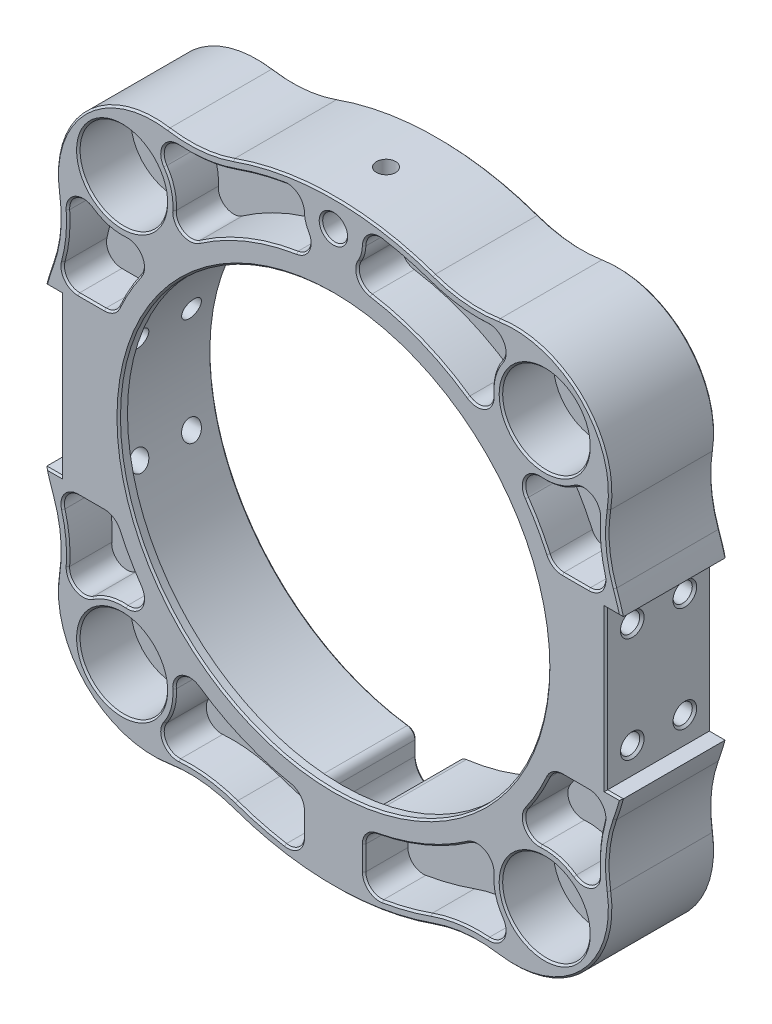
from build123d import *

# Parameters (mm, degrees)
SKETCH1_R                       = 5
EXTRUDE1_DEPTH                  = 12
SKETCH2_R                       = 24.5
EXTRUDE2_DEPTH                  = 13
SKETCH3_R                       = 5
FLAG_STOP_DEPTH_DEPTH           = 6
EXTRUDE4_DEPTH                  = 11
SKETCH5_R                       = 2.5
EXTRUDE5_DEPTH                  = 7
SKETCH6_R                       = 4.3
FLAG_MOUNTING_DEPTH_DEPTH       = 5
SKETCH7_W                       = 12
SKETCH7_H                       = 18
EXTRUDE7_DEPTH                  = 4
SKETCH8_R                       = 1.1
EXTRUDE8_DEPTH                  = 17
CHAMFER1_SIZE                   = 0.25
CHAMFER1_OF_MIRROR1_SIZE        = 0.25
SKETCH9_R                       = 1.4224
EXTRUDE9_DEPTH                  = 13
SKETCH11_R                      = 1.4224
EXTRUDE11_DEPTH                 = 43
EXTRUDE12_DEPTH                 = 5
EXTRUDE13_DEPTH                 = 5
EXTRUDE14_DEPTH                 = 5
MIRROR7_COPY_1_DEPTH            = 5
MIRROR8_COPY_1_DEPTH            = 5
MIRROR8_COPY_2_DEPTH            = 5
MIRROR8_COPY_3_DEPTH            = 5
MIRROR8_COPY_4_DEPTH            = 5
CHAMFER2_SIZE                   = 0.2
CHAMFER3_SIZE                   = 0.2
F_2_56_TAPPED_HOLE1_D           = 1.778
F_2_56_TAPPED_HOLE1_DEPTH       = 3.1
F_2_56_TAPPED_HOLE1_CBORE_D     = 2.1844
F_2_56_TAPPED_HOLE1_CBORE_DEPTH = 3
F_2_56_TAPPED_HOLE1_TIP         = 0.53416509


with BuildPart() as part:
    # Sketch1 → Extrude1 (new body)
    with BuildSketch(Plane.XY):
        with BuildLine():
            ThreePointArc((-32.122002379, 11.444953611), (-34.1, 0), (-32.122002379, -11.444953611))
            ThreePointArc((-32.122002379, -11.444953611), (-31.315364719, -15.101184494), (-31.439353074, -18.843284904))
            ThreePointArc((-31.439353074, -18.843284904), (-28.354981926, -28.354981926), (-18.843284904, -31.439353074))
            ThreePointArc((-18.843284904, -31.439353074), (-15.101184494, -31.315364719), (-11.444953611, -32.122002379))
            ThreePointArc((-11.444953611, -32.122002379), (0, -34.1), (11.444953611, -32.122002379))
            ThreePointArc((11.444953611, -32.122002379), (15.101184494, -31.315364719), (18.843284904, -31.439353074))
            ThreePointArc((18.843284904, -31.439353074), (28.354981926, -28.354981925), (31.439353074, -18.843284904))
            ThreePointArc((31.439353074, -18.843284904), (31.315364719, -15.101184494), (32.122002379, -11.444953611))
            ThreePointArc((32.122002379, -11.444953611), (34.1, 0), (32.122002379, 11.444953611))
            ThreePointArc((32.122002379, 11.444953611), (31.315364719, 15.101184494), (31.439353074, 18.843284904))
            ThreePointArc((31.439353074, 18.843284904), (28.354981926, 28.354981926), (18.843284904, 31.439353074))
            ThreePointArc((18.843284904, 31.439353074), (15.101184494, 31.31536472), (11.444953611, 32.122002379))
            ThreePointArc((11.444953611, 32.122002379), (0, 34.1), (-11.444953611, 32.122002379))
            ThreePointArc((-11.444953611, 32.122002379), (-15.101184494, 31.315364719), (-18.843284904, 31.439353074))
            ThreePointArc((-18.843284904, 31.439353074), (-28.354981926, 28.354981926), (-31.439353074, 18.843284904))
            ThreePointArc((-31.439353074, 18.843284904), (-31.315364719, 15.101184494), (-32.122002379, 11.444953611))
        make_face()
        with Locations((-24.112341238, 24.112341238)):
            Circle(SKETCH1_R, mode=Mode.SUBTRACT)
        with Locations((24.112341238, 24.112341239)):
            Circle(SKETCH1_R, mode=Mode.SUBTRACT)
        with Locations((24.112341238, -24.112341238)):
            Circle(SKETCH1_R, mode=Mode.SUBTRACT)
        with Locations((-24.112341238, -24.112341238)):
            Circle(SKETCH1_R, mode=Mode.SUBTRACT)
    extrude(amount=EXTRUDE1_DEPTH)

    # Sketch2 → Extrude2 (cut, through all)
    with BuildSketch(Plane.XY.offset(12)):
        Circle(SKETCH2_R)
    extrude(amount=-EXTRUDE2_DEPTH, mode=Mode.SUBTRACT)

    # Sketch3 → Flag Stop Depth (add)
    with BuildSketch(Plane(origin=(0, 0, 0), x_dir=(-1, 0, 0), z_dir=(0, 0, -1))):
        with Locations((24.112341238, 24.112341238)):
            Circle(SKETCH3_R)
        with Locations((24.112341238, -24.112341238)):
            Circle(SKETCH3_R)
        with Locations((-24.112341238, -24.112341238)):
            Circle(SKETCH3_R)
        with Locations((-24.112341238, 24.112341239)):
            Circle(SKETCH3_R)
    extrude(amount=-FLAG_STOP_DEPTH_DEPTH)

    # Sketch4 → Extrude4 (cut)
    with BuildSketch(Plane(origin=(0, 0, 0), x_dir=(-1, 0, 0), z_dir=(0, 0, -1))):
        with BuildLine():
            Line((-2.5, -28.3), (-2.5, -26.671332925))
            ThreePointArc((-2.5, -26.671332925), (-2.74829809, -26.011829902), (-3.369888476, -25.67983356))
            ThreePointArc((-3.369888476, -25.67983356), (-24.176682626, -9.289672611), (-19.698530393, 16.816001319))
            ThreePointArc((-19.698530393, 16.816001319), (-19.088675937, 17.359183498), (-18.354926101, 17.717764752))
            ThreePointArc((-18.354926101, 17.717764752), (-17.960512242, 17.960512242), (-17.717764752, 18.354926101))
            ThreePointArc((-17.717764752, 18.354926101), (-17.359183498, 19.088675937), (-16.816001319, 19.698530393))
            ThreePointArc((-16.816001319, 19.698530393), (0, 25.9), (16.816001319, 19.698530393))
            ThreePointArc((16.816001319, 19.698530393), (17.359183498, 19.088675937), (17.717764752, 18.354926101))
            ThreePointArc((17.717764752, 18.354926101), (17.960512242, 17.960512242), (18.354926101, 17.717764752))
            ThreePointArc((18.354926101, 17.717764752), (19.088675937, 17.359183498), (19.698530393, 16.816001319))
            ThreePointArc((19.698530393, 16.816001319), (24.176682626, -9.289672611), (3.369888476, -25.67983356))
            ThreePointArc((3.369888476, -25.67983356), (2.74829809, -26.011829902), (2.5, -26.671332925))
            Line((2.5, -26.671332925), (2.5, -28.3))
            ThreePointArc((2.5, -28.3), (0, -30.8), (-2.5, -28.3))
        make_face()
    extrude(amount=-EXTRUDE4_DEPTH, mode=Mode.SUBTRACT)

    # Sketch5 → Extrude5 (cut, through all)
    with BuildSketch(Plane.XY.offset(6)):
        with Locations((-24.112341238, 24.112341238)):
            Circle(SKETCH5_R)
        with Locations((24.112341238, 24.112341239)):
            Circle(SKETCH5_R)
        with Locations((24.112341238, -24.112341238)):
            Circle(SKETCH5_R)
        with Locations((-24.112341238, -24.112341238)):
            Circle(SKETCH5_R)
    extrude(amount=-EXTRUDE5_DEPTH, mode=Mode.SUBTRACT)

    # Sketch6 → Flag Mounting Depth (cut)
    with BuildSketch(Plane(origin=(0, 0, 0), x_dir=(-1, 0, 0), z_dir=(0, 0, -1))):
        with Locations((-24.112341238, 24.112341239)):
            Circle(SKETCH6_R)
        with Locations((24.112341238, 24.112341238)):
            Circle(SKETCH6_R)
        with Locations((24.112341238, -24.112341238)):
            Circle(SKETCH6_R)
        with Locations((-24.112341238, -24.112341238)):
            Circle(SKETCH6_R)
    extrude(amount=-FLAG_MOUNTING_DEPTH_DEPTH, mode=Mode.SUBTRACT)

    # Sketch7 → Extrude7 (cut, through all)
    with BuildSketch(Plane(origin=(31.1, 0, 0), x_dir=(0, 0, -1), z_dir=(1, 0, 0))):
        with Locations((-6, 0)):
            Rectangle(SKETCH7_W, SKETCH7_H)
    extrude7 = extrude(amount=EXTRUDE7_DEPTH, mode=Mode.SUBTRACT)

    # Sketch8 → Extrude8 (cut)
    with BuildSketch(Plane(origin=(31.1, 0, 0), x_dir=(0, 0, -1), z_dir=(1, 0, 0))):
        with Locations((-9, 6)):
            Circle(SKETCH8_R)
        with Locations((-3, 6)):
            Circle(SKETCH8_R)
        with Locations((-9, -6)):
            Circle(SKETCH8_R)
        with Locations((-3, -6)):
            Circle(SKETCH8_R)
    extrude8 = extrude(amount=-EXTRUDE8_DEPTH, mode=Mode.SUBTRACT)

    # Chamfer1
    chamfer1_edges = [part.edges().sort_by_distance(p)[0] for p in [
        (31.1, 6, 10.1),
        (31.1, 6, 4.1),
        (31.1, -6, 10.1),
        (31.1, -6, 4.1),
    ]]
    chamfer(chamfer1_edges, length=CHAMFER1_SIZE)

    # Mirror1: Extrude7, Extrude8 across plane
    add(extrude7.mirror(Plane(origin=(0, 0, 0), x_dir=(0, 0, 1), z_dir=(1, 0, 0))), mode=Mode.SUBTRACT)
    add(extrude8.mirror(Plane(origin=(0, 0, 0), x_dir=(0, 0, 1), z_dir=(1, 0, 0))), mode=Mode.SUBTRACT)

    # Chamfer1 of Mirror1
    chamfer1_of_mirror1_edges = [part.edges().sort_by_distance(p)[0] for p in [
        (-31.1, 6, 10.1),
        (-31.1, 6, 4.1),
        (-31.1, -6, 10.1),
        (-31.1, -6, 4.1),
    ]]
    chamfer(chamfer1_of_mirror1_edges, length=CHAMFER1_OF_MIRROR1_SIZE)

    # Sketch9 → Extrude9 (cut, through all)
    with BuildSketch(Plane(origin=(0, 0, 0), x_dir=(-1, 0, 0), z_dir=(0, 0, -1))):
        with Locations((0, 31)):
            Circle(SKETCH9_R)
    extrude(amount=-EXTRUDE9_DEPTH, mode=Mode.SUBTRACT)

    # Sketch11 → Extrude11 (cut)
    with BuildSketch(Plane(origin=(0, 0, 0), x_dir=(1, 0, 0), z_dir=(0, 1, 0))):
        with Locations(Location((0, -5.5, 0), (0, 0, 270))):  # turned: the seam where the file's is
            Circle(SKETCH11_R)
    extrude(amount=-EXTRUDE11_DEPTH, mode=Mode.SUBTRACT)

    # Sketch12 → Extrude12 (cut)
    with BuildSketch(Plane(origin=(0, 0, 0), x_dir=(-1, 0, 0), z_dir=(0, 0, -1))):
        with BuildLine():
            ThreePointArc((-4.224385639, 26.566229804), (-10.059879618, 24.948122616), (-15.385556887, 22.065689187))
            ThreePointArc((-15.385556887, 22.065689187), (-17.256662277, 21.982875917), (-18.131026227, 23.639191438))
            ThreePointArc((-18.131026227, 23.639191438), (-18.322112756, 25.684999536), (-19.192239457, 27.546376542))
            ThreePointArc((-19.192239457, 27.546376542), (-19.278714432, 29.412564625), (-17.631227608, 30.293429566))
            ThreePointArc((-17.631227608, 30.293429566), (-14.32419464, 30.397732089), (-11.109324473, 31.180008175))
            ThreePointArc((-11.109324473, 31.180008175), (-8.357386403, 32.027552084), (-5.542200264, 32.632713896))
            ThreePointArc((-5.542200264, 32.632713896), (-4.131919638, 32.254349629), (-3.499455756, 30.93827957))
            ThreePointArc((-3.499455756, 30.93827957), (-3.364163573, 30.034389595), (-2.999470844, 29.196344086))
            ThreePointArc((-2.999470844, 29.196344086), (-2.912814896, 27.555691101), (-4.224385639, 26.566229804))
        make_face()
    extrude12 = extrude(amount=-EXTRUDE12_DEPTH, mode=Mode.SUBTRACT)

    # Sketch13 → Extrude13 (cut)
    with BuildSketch(Plane(origin=(0, 0, 0), x_dir=(-1, 0, 0), z_dir=(0, 0, -1))):
        with BuildLine():
            Line((-29.143573514, 10), (-26.129676615, 10))
            ThreePointArc((-26.129676615, 10), (-25.179281731, 10.28056148), (-24.53362307, 11.032286213))
            ThreePointArc((-24.53362307, 11.032286213), (-23.40110504, 13.266434447), (-22.065689186, 15.385556887))
            ThreePointArc((-22.065689186, 15.385556887), (-21.982875917, 17.256662277), (-23.639191438, 18.131026227))
            ThreePointArc((-23.639191438, 18.131026227), (-25.684999536, 18.322112756), (-27.546376542, 19.192239458))
            ThreePointArc((-27.546376542, 19.192239458), (-29.412564624, 19.278714432), (-30.293429565, 17.631227608))
            ThreePointArc((-30.293429565, 17.631227608), (-30.329983086, 14.900761587), (-30.830311451, 12.216277955))
            ThreePointArc((-30.830311451, 12.216277955), (-30.536140644, 10.690161904), (-29.143573514, 10))
        make_face()
    extrude13 = extrude(amount=-EXTRUDE13_DEPTH, mode=Mode.SUBTRACT)

    # Sketch14 → Extrude14 (cut)
    with BuildSketch(Plane(origin=(0, 0, 0), x_dir=(-1, 0, 0), z_dir=(0, 0, -1))):
        with BuildLine():
            Line((-3.5, -28.164871738), (-3.5, -30.907280696))
            ThreePointArc((-3.5, -30.907280696), (-4.120920475, -32.244321991), (-5.543062201, -32.632567497))
            ThreePointArc((-5.543062201, -32.632567497), (-8.35780938, -32.027441708), (-11.109324473, -31.180008174))
            ThreePointArc((-11.109324473, -31.180008174), (-14.32419464, -30.397732089), (-17.631227608, -30.293429565))
            ThreePointArc((-17.631227608, -30.293429565), (-19.278714432, -29.412564624), (-19.192239458, -27.546376542))
            ThreePointArc((-19.192239458, -27.546376542), (-18.322112756, -25.684999536), (-18.131026227, -23.639191438))
            ThreePointArc((-18.131026227, -23.639191438), (-17.256662278, -21.982875917), (-15.385556887, -22.065689186))
            ThreePointArc((-15.385556887, -22.065689186), (-10.390719654, -24.812153173), (-4.929319372, -26.444504354))
            ThreePointArc((-4.929319372, -26.444504354), (-3.903951877, -27.046545108), (-3.5, -28.164871738))
        make_face()
        with BuildLine():
            Line((3.5, -28.164871738), (3.5, -30.907280696))
            ThreePointArc((3.5, -30.907280696), (4.120920475, -32.244321991), (5.543062201, -32.632567497))
            ThreePointArc((5.543062201, -32.632567497), (8.35780938, -32.027441708), (11.109324473, -31.180008174))
            ThreePointArc((11.109324473, -31.180008174), (14.32419464, -30.397732089), (17.631227608, -30.293429566))
            ThreePointArc((17.631227608, -30.293429566), (19.278714432, -29.412564624), (19.192239458, -27.546376542))
            ThreePointArc((19.192239458, -27.546376542), (18.322112756, -25.684999536), (18.131026227, -23.639191438))
            ThreePointArc((18.131026227, -23.639191438), (17.256662277, -21.982875917), (15.385556887, -22.065689186))
            ThreePointArc((15.385556887, -22.065689186), (10.390719654, -24.812153173), (4.929319372, -26.444504354))
            ThreePointArc((4.929319372, -26.444504354), (3.903951877, -27.046545108), (3.5, -28.164871738))
        make_face()
    extrude14 = extrude(amount=-EXTRUDE14_DEPTH, mode=Mode.SUBTRACT)

    # Mirror2: Extrude12 across plane
    add(extrude12.mirror(Plane(origin=(0, 0, 0), x_dir=(0, 0, 1), z_dir=(1, 0, 0))), mode=Mode.SUBTRACT)

    # Mirror6: Extrude13 across plane
    add(extrude13.mirror(Plane.ZX), mode=Mode.SUBTRACT)

    # Mirror7: Extrude13 across plane
    add(extrude13.mirror(Plane(origin=(0, 0, 0), x_dir=(0, 0, 1), z_dir=(1, 0, 0))), mode=Mode.SUBTRACT)

    # Mirror7 copy 1 sketch → Mirror7 copy 1 (cut)
    with BuildSketch(Plane(origin=(0, 0, 0), x_dir=(1, 0, 0), z_dir=(0, 0, -1))):
        with BuildLine():
            Line((-29.143573514, 10), (-26.129676615, 10))
            ThreePointArc((-26.129676615, 10), (-25.179281731, 10.28056148), (-24.53362307, 11.032286213))
            ThreePointArc((-24.53362307, 11.032286213), (-23.40110504, 13.266434447), (-22.065689186, 15.385556887))
            ThreePointArc((-22.065689186, 15.385556887), (-21.982875917, 17.256662277), (-23.639191438, 18.131026227))
            ThreePointArc((-23.639191438, 18.131026227), (-25.684999536, 18.322112756), (-27.546376542, 19.192239458))
            ThreePointArc((-27.546376542, 19.192239458), (-29.412564624, 19.278714432), (-30.293429565, 17.631227608))
            ThreePointArc((-30.293429565, 17.631227608), (-30.329983086, 14.900761587), (-30.830311451, 12.216277955))
            ThreePointArc((-30.830311451, 12.216277955), (-30.536140644, 10.690161904), (-29.143573514, 10))
        make_face()
    extrude(amount=-MIRROR7_COPY_1_DEPTH, mode=Mode.SUBTRACT)

    # Mirror8: Extrude14, Extrude12, Extrude13 across plane
    add(extrude14.mirror(Plane.XY.offset(6)), mode=Mode.SUBTRACT)
    add(extrude12.mirror(Plane.XY.offset(6)), mode=Mode.SUBTRACT)
    add(extrude13.mirror(Plane.XY.offset(6)), mode=Mode.SUBTRACT)

    # Mirror8 copy 1 sketch → Mirror8 copy 1 (cut)
    with BuildSketch(Plane.XY.offset(12)):
        with BuildLine():
            ThreePointArc((-4.224385639, 26.566229804), (-10.059879618, 24.948122616), (-15.385556887, 22.065689187))
            ThreePointArc((-15.385556887, 22.065689187), (-17.256662277, 21.982875917), (-18.131026227, 23.639191438))
            ThreePointArc((-18.131026227, 23.639191438), (-18.322112756, 25.684999536), (-19.192239457, 27.546376542))
            ThreePointArc((-19.192239457, 27.546376542), (-19.278714432, 29.412564625), (-17.631227608, 30.293429566))
            ThreePointArc((-17.631227608, 30.293429566), (-14.32419464, 30.397732089), (-11.109324473, 31.180008175))
            ThreePointArc((-11.109324473, 31.180008175), (-8.357386403, 32.027552084), (-5.542200264, 32.632713896))
            ThreePointArc((-5.542200264, 32.632713896), (-4.131919638, 32.254349629), (-3.499455756, 30.93827957))
            ThreePointArc((-3.499455756, 30.93827957), (-3.364163573, 30.034389595), (-2.999470844, 29.196344086))
            ThreePointArc((-2.999470844, 29.196344086), (-2.912814896, 27.555691101), (-4.224385639, 26.566229804))
        make_face()
    extrude(amount=-MIRROR8_COPY_1_DEPTH, mode=Mode.SUBTRACT)

    # Mirror8 copy 2 sketch → Mirror8 copy 2 (cut)
    with BuildSketch(Plane.XY.offset(12)):
        with BuildLine():
            Line((-29.143573514, 10), (-26.129676615, 10))
            ThreePointArc((-26.129676615, 10), (-25.179281731, 10.28056148), (-24.53362307, 11.032286213))
            ThreePointArc((-24.53362307, 11.032286213), (-23.40110504, 13.266434447), (-22.065689186, 15.385556887))
            ThreePointArc((-22.065689186, 15.385556887), (-21.982875917, 17.256662277), (-23.639191438, 18.131026227))
            ThreePointArc((-23.639191438, 18.131026227), (-25.684999536, 18.322112756), (-27.546376542, 19.192239458))
            ThreePointArc((-27.546376542, 19.192239458), (-29.412564624, 19.278714432), (-30.293429565, 17.631227608))
            ThreePointArc((-30.293429565, 17.631227608), (-30.329983086, 14.900761587), (-30.830311451, 12.216277955))
            ThreePointArc((-30.830311451, 12.216277955), (-30.536140644, 10.690161904), (-29.143573514, 10))
        make_face()
    extrude(amount=-MIRROR8_COPY_2_DEPTH, mode=Mode.SUBTRACT)

    # Mirror8 copy 3 sketch → Mirror8 copy 3 (cut)
    with BuildSketch(Plane.XY.offset(12)):
        with BuildLine():
            Line((-29.143573514, -10), (-26.129676615, -10))
            ThreePointArc((-26.129676615, -10), (-25.179281731, -10.28056148), (-24.53362307, -11.032286213))
            ThreePointArc((-24.53362307, -11.032286213), (-23.40110504, -13.266434447), (-22.065689186, -15.385556887))
            ThreePointArc((-22.065689186, -15.385556887), (-21.982875917, -17.256662277), (-23.639191438, -18.131026227))
            ThreePointArc((-23.639191438, -18.131026227), (-25.684999536, -18.322112756), (-27.546376542, -19.192239458))
            ThreePointArc((-27.546376542, -19.192239458), (-29.412564624, -19.278714432), (-30.293429565, -17.631227608))
            ThreePointArc((-30.293429565, -17.631227608), (-30.329983086, -14.900761587), (-30.830311451, -12.216277955))
            ThreePointArc((-30.830311451, -12.216277955), (-30.536140644, -10.690161904), (-29.143573514, -10))
        make_face()
    extrude(amount=-MIRROR8_COPY_3_DEPTH, mode=Mode.SUBTRACT)

    # Mirror8 copy 4 sketch → Mirror8 copy 4 (cut)
    with BuildSketch(Plane(origin=(0, 0, 12), x_dir=(-1, 0, 0), z_dir=(0, 0, 1))):
        with BuildLine():
            Line((-29.143573514, 10), (-26.129676615, 10))
            ThreePointArc((-26.129676615, 10), (-25.179281731, 10.28056148), (-24.53362307, 11.032286213))
            ThreePointArc((-24.53362307, 11.032286213), (-23.40110504, 13.266434447), (-22.065689186, 15.385556887))
            ThreePointArc((-22.065689186, 15.385556887), (-21.982875917, 17.256662277), (-23.639191438, 18.131026227))
            ThreePointArc((-23.639191438, 18.131026227), (-25.684999536, 18.322112756), (-27.546376542, 19.192239458))
            ThreePointArc((-27.546376542, 19.192239458), (-29.412564624, 19.278714432), (-30.293429565, 17.631227608))
            ThreePointArc((-30.293429565, 17.631227608), (-30.329983086, 14.900761587), (-30.830311451, 12.216277955))
            ThreePointArc((-30.830311451, 12.216277955), (-30.536140644, 10.690161904), (-29.143573514, 10))
        make_face()
    extrude(amount=-MIRROR8_COPY_4_DEPTH, mode=Mode.SUBTRACT)

    # Chamfer2
    chamfer2_edges = [part.edges().sort_by_distance(p)[0] for p in [
        (-31.315364719, -15.101184494, 12),
        (-28.354981926, -28.354981926, 12),
        (-15.101184494, -31.315364719, 12),
        (32.529420141, 10.22970309, 12),
        (31.995440097, 9, 12),
        (31.1, 0, 12),
        (31.995440097, -9, 12),
        (0, -34.1, 12),
        (15.101184494, -31.315364719, 12),
        (-32.529420141, -10.22970309, 12),
        (-31.995440097, -9, 12),
        (-31.995440097, 9, 12),
        (-31.1, 0, 12),
        (28.354981926, -28.354981925, 12),
        (31.315364719, -15.101184494, 12),
        (1.4224, 31, 12),
        (32.529420141, -10.22970309, 12),
        (31.315364719, 15.101184494, 12),
        (28.354981926, 28.354981926, 12),
        (-29.112341238, 24.112341238, 12),
        (-31.315364719, 15.101184494, 12),
        (15.101184494, 31.31536472, 12),
        (19.112341238, 24.112341239, 12),
        (0, 34.1, 12),
        (-15.101184494, 31.315364719, 12),
        (19.112341238, -24.112341238, 12),
        (-28.354981926, 28.354981926, 12),
        (-29.112341238, -24.112341238, 12),
        (17.256662277, 21.982875917, 12),
        (10.059879618, 24.948122616, 12),
        (2.912814896, 27.555691101, 12),
        (3.364163573, 30.034389595, 12),
        (4.131919638, 32.254349629, 12),
        (8.357386403, 32.027552084, 12),
        (14.32419464, 30.397732089, 12),
        (19.278714432, 29.412564625, 12),
        (18.322112756, 25.684999536, 12),
        (19.278714432, -29.412564624, 12),
        (14.32419464, -30.397732089, 12),
        (8.35780938, -32.027441708, 12),
        (4.120920475, -32.244321991, 12),
        (3.5, -29.536076217, 12),
        (3.903951877, -27.046545108, 12),
        (10.390719654, -24.812153173, 12),
        (17.256662278, -21.982875917, 12),
        (18.322112756, -25.684999536, 12),
        (-19.278714432, -29.412564624, 12),
        (-18.322112756, -25.684999536, 12),
        (-17.256662277, -21.982875917, 12),
        (-10.390719654, -24.812153173, 12),
        (-3.903951877, -27.046545108, 12),
        (-3.5, -29.536076217, 12),
        (-4.120920475, -32.244321991, 12),
        (-8.35780938, -32.027441708, 12),
        (-14.32419464, -30.397732089, 12),
        (-17.256662277, 21.982875917, 12),
        (-10.059879618, 24.948122616, 12),
        (-2.912814896, 27.555691101, 12),
        (-3.364163573, 30.034389595, 12),
        (-4.131919638, 32.254349629, 12),
        (-8.357386403, 32.027552084, 12),
        (-14.32419464, 30.397732089, 12),
        (-19.278714432, 29.412564625, 12),
        (-18.322112756, 25.684999536, 12),
        (-30.536140644, -10.690161904, 12),
        (-27.636625065, -10, 12),
        (-25.179281731, -10.28056148, 12),
        (-23.40110504, -13.266434447, 12),
        (-21.982875917, -17.256662277, 12),
        (-25.684999536, -18.322112756, 12),
        (-29.412564624, -19.278714432, 12),
        (-30.329983086, -14.900761587, 12),
        (-24.5, 0, 12),
        (-30.536140644, 10.690161904, 12),
        (-27.636625065, 10, 12),
        (-25.179281731, 10.28056148, 12),
        (-23.40110504, 13.266434447, 12),
        (-21.982875917, 17.256662277, 12),
        (-25.684999536, 18.322112756, 12),
        (-29.412564624, 19.278714432, 12),
        (-30.329983086, 14.900761587, 12),
        (30.536140644, -10.690161904, 12),
        (27.636625065, -10, 12),
        (25.179281731, -10.28056148, 12),
        (23.40110504, -13.266434447, 12),
        (21.982875917, -17.256662277, 12),
        (25.684999536, -18.322112756, 12),
        (29.412564624, -19.278714432, 12),
        (30.329983086, -14.900761587, 12),
        (30.536140644, 10.690161904, 12),
        (27.636625065, 10, 12),
        (25.179281731, 10.28056148, 12),
        (23.40110504, 13.266434447, 12),
        (21.982875917, 17.256662277, 12),
        (25.684999536, 18.322112756, 12),
        (29.412564624, 19.278714432, 12),
        (30.329983086, 14.900761587, 12),
        (-32.529420141, 10.22970309, 12),
    ]]
    chamfer(chamfer2_edges, length=CHAMFER2_SIZE)

    # Chamfer3
    chamfer3_edges = [part.edges().sort_by_distance(p)[0] for p in [
        (-28.354981926, 28.354981926, 0),
        (-15.101184494, 31.315364719, 0),
        (28.412341238, 24.112341239, 0),
        (0, 34.1, 0),
        (15.101184494, 31.31536472, 0),
        (-19.812341238, 24.112341238, 0),
        (28.354981926, 28.354981926, 0),
        (-19.812341238, -24.112341238, 0),
        (31.315364719, 15.101184494, 0),
        (28.412341238, -24.112341238, 0),
        (32.529420141, -10.22970309, 0),
        (31.315364719, -15.101184494, 0),
        (32.529420141, 10.22970309, 0),
        (28.354981926, -28.354981925, 0),
        (15.101184494, -31.315364719, 0),
        (31.995440097, -9, 0),
        (31.1, 0, 0),
        (31.995440097, 9, 0),
        (0, -34.1, 0),
        (-15.101184494, -31.315364719, 0),
        (-28.354981926, -28.354981926, 0),
        (-31.315364719, -15.101184494, 0),
        (-32.529420141, 10.22970309, 0),
        (-31.315364719, 15.101184494, 0),
        (-32.529420141, -10.22970309, 0),
        (-31.995440097, 9, 0),
        (-31.995440097, -9, 0),
        (-31.1, 0, 0),
        (1.4224, 31, 0),
        (17.256662277, 21.982875917, 0),
        (10.059879618, 24.948122616, 0),
        (2.912814896, 27.555691101, 0),
        (3.364163573, 30.034389595, 0),
        (4.131919638, 32.254349629, 0),
        (8.357386403, 32.027552084, 0),
        (14.32419464, 30.397732089, 0),
        (19.278714432, 29.412564625, 0),
        (18.322112756, 25.684999536, 0),
        (30.536140644, 10.690161904, 0),
        (27.636625065, 10, 0),
        (25.179281731, 10.28056148, 0),
        (23.40110504, 13.266434447, 0),
        (21.982875917, 17.256662277, 0),
        (25.684999536, 18.322112756, 0),
        (29.412564624, 19.278714432, 0),
        (30.329983086, 14.900761587, 0),
        (19.278714432, -29.412564624, 0),
        (14.32419464, -30.397732089, 0),
        (8.35780938, -32.027441708, 0),
        (4.120920475, -32.244321991, 0),
        (3.5, -29.536076217, 0),
        (3.903951877, -27.046545108, 0),
        (10.390719654, -24.812153173, 0),
        (17.256662278, -21.982875917, 0),
        (18.322112756, -25.684999536, 0),
        (-19.278714432, -29.412564624, 0),
        (-18.322112756, -25.684999536, 0),
        (-17.256662277, -21.982875917, 0),
        (-10.390719654, -24.812153173, 0),
        (-3.903951877, -27.046545108, 0),
        (-3.5, -29.536076217, 0),
        (-4.120920475, -32.244321991, 0),
        (-8.35780938, -32.027441708, 0),
        (-14.32419464, -30.397732089, 0),
        (-17.256662277, 21.982875917, 0),
        (-10.059879618, 24.948122616, 0),
        (-2.912814896, 27.555691101, 0),
        (-3.364163573, 30.034389595, 0),
        (-4.131919638, 32.254349629, 0),
        (-8.357386403, 32.027552084, 0),
        (-14.32419464, 30.397732089, 0),
        (-19.278714432, 29.412564625, 0),
        (-18.322112756, 25.684999536, 0),
        (30.536140644, -10.690161904, 0),
        (27.636625065, -10, 0),
        (25.179281731, -10.28056148, 0),
        (23.40110504, -13.266434447, 0),
        (21.982875917, -17.256662277, 0),
        (25.684999536, -18.322112756, 0),
        (29.412564624, -19.278714432, 0),
        (30.329983086, -14.900761587, 0),
        (-30.536140644, -10.690161904, 0),
        (-27.636625065, -10, 0),
        (-25.179281731, -10.28056148, 0),
        (-23.40110504, -13.266434447, 0),
        (-21.982875917, -17.256662277, 0),
        (-25.684999536, -18.322112756, 0),
        (-29.412564624, -19.278714432, 0),
        (-30.329983086, -14.900761587, 0),
        (-30.536140644, 10.690161904, 0),
        (-27.636625065, 10, 0),
        (-25.179281731, 10.28056148, 0),
        (-23.40110504, 13.266434447, 0),
        (-21.982875917, 17.256662277, 0),
        (-25.684999536, 18.322112756, 0),
        (-29.412564624, 19.278714432, 0),
        (-30.329983086, 14.900761587, 0),
        (19.088675937, 17.359183498, 0),
        (24.176682626, -9.289672611, 0),
        (2.74829809, -26.011829902, 0),
        (2.5, -27.485666463, 0),
        (0, -30.8, 0),
        (-2.5, -27.485666463, 0),
        (-2.74829809, -26.011829902, 0),
        (-24.176682626, -9.289672611, 0),
        (-19.088675937, 17.359183498, 0),
        (-17.960512242, 17.960512242, 0),
        (-17.359183498, 19.088675937, 0),
        (0, 25.9, 0),
        (17.359183498, 19.088675937, 0),
        (17.960512242, 17.960512242, 0),
    ]]
    chamfer(chamfer3_edges, length=CHAMFER3_SIZE)

    # 2-56 Tapped Hole1
    with Locations(Plane(origin=(0, 34.1, 6), x_dir=(1, 0, 0), z_dir=(0, 1, 0))):
        with Locations((0, 0)):
            CounterBoreHole(F_2_56_TAPPED_HOLE1_D / 2, F_2_56_TAPPED_HOLE1_CBORE_D / 2, F_2_56_TAPPED_HOLE1_CBORE_DEPTH, depth=F_2_56_TAPPED_HOLE1_DEPTH)
            with Locations((0, 0, -(F_2_56_TAPPED_HOLE1_DEPTH + F_2_56_TAPPED_HOLE1_TIP / 2))):  # 118° drill point
                Cone(0, F_2_56_TAPPED_HOLE1_D / 2, F_2_56_TAPPED_HOLE1_TIP, mode=Mode.SUBTRACT)


solid = part.part
